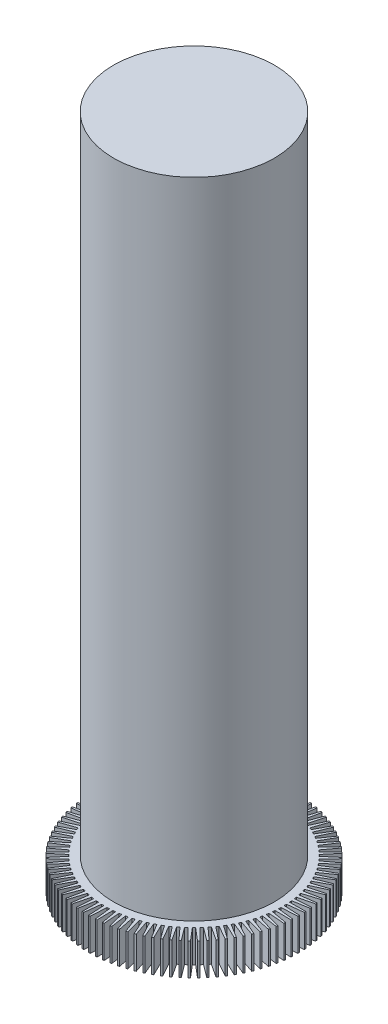
from build123d import *

# Parameters (mm, degrees)
BOSS_EXTRUDE2_DEPTH = 1
SKETCH2_R           = 2.5
BOSS_EXTRUDE3_DEPTH = 20


with BuildPart() as part:
    # Sketch1 → Boss-Extrude2 (new body)
    with BuildSketch(Plane(origin=(0, 0, 0), x_dir=(1, 0, 0), z_dir=(0, 1, 0))):
        with BuildLine():
            Line((-0.025, 3.249545417), (-0.05, 2.749545417))
            ThreePointArc((-0.05, 2.749545417), (-0.086379587, 2.748643041), (-0.122744049, 2.747259343))
            Line((-0.122744049, 2.747259343), (-0.179089977, 3.244702944))
            Line((-0.179089977, 3.244702944), (-0.228991313, 3.241563418))
            Line((-0.228991313, 3.241563418), (-0.222546722, 2.740980291))
            ThreePointArc((-0.222546722, 2.740980291), (-0.258797862, 2.737795403), (-0.295003683, 2.734131092))
            Line((-0.295003683, 2.734131092), (-0.382473167, 3.227055112))
            Line((-0.382473167, 3.227055112), (-0.432078902, 3.22078845))
            Line((-0.432078902, 3.22078845), (-0.394215153, 2.721597768))
            ThreePointArc((-0.394215153, 2.721597768), (-0.430194779, 2.716142937), (-0.466099072, 2.710212474))
            Line((-0.466099072, 2.710212474), (-0.584346911, 3.196671567))
            Line((-0.584346911, 3.196671567), (-0.633461273, 3.187302501))
            Line((-0.633461273, 3.187302501), (-0.564327797, 2.691474343))
            ThreePointArc((-0.564327797, 2.691474343), (-0.599893914, 2.683771095), (-0.635354981, 2.675597886))
            Line((-0.635354981, 2.675597886), (-0.783914504, 3.153672219))
            Line((-0.783914504, 3.153672219), (-0.832343662, 3.141237725))
            Line((-0.832343662, 3.141237725), (-0.732213298, 2.650728897))
            ThreePointArc((-0.732213298, 2.650728897), (-0.767225542, 2.640807636), (-0.802103435, 2.630423935))
            Line((-0.802103435, 2.630423935), (-0.980388345, 3.098226769))
            Line((-0.980388345, 3.098226769), (-1.027941171, 3.082775919))
            Line((-1.027941171, 3.082775919), (-0.897209086, 2.599522236))
            ThreePointArc((-0.897209086, 2.599522236), (-0.931529281, 2.587422115), (-0.965686352, 2.574868903))
            Line((-0.965686352, 2.574868903), (-1.172993041, 3.030554032))
            Line((-1.172993041, 3.030554032), (-1.219481865, 3.012147805))
            Line((-1.219481865, 3.012147805), (-1.058664001, 2.538056448))
            ThreePointArc((-1.058664001, 2.538056448), (-1.092156699, 2.523825221), (-1.125458147, 2.50915204))
            Line((-1.125458147, 2.50915204), (-1.360968469, 2.950921084))
            Line((-1.360968469, 2.950921084), (-1.406209822, 2.929632119))
            Line((-1.406209822, 2.929632119), (-1.215940852, 2.466574111))
            ThreePointArc((-1.215940852, 2.466574111), (-1.248473874, 2.450267942), (-1.280788273, 2.4335327))
            Line((-1.280788273, 2.4335327), (-1.543572777, 2.859642198))
            Line((-1.543572777, 2.859642198), (-1.587388111, 2.835554514))
            Line((-1.587388111, 2.835554514), (-1.368418941, 2.385357332))
            ThreePointArc((-1.368418941, 2.385357332), (-1.399863893, 2.367040574), (-1.431063712, 2.348309318))
            Line((-1.431063712, 2.348309318), (-1.720085308, 2.757077611))
            Line((-1.720085308, 2.757077611), (-1.762301704, 2.730286271))
            Line((-1.762301704, 2.730286271), (-1.515496505, 2.294726638))
            ThreePointArc((-1.515496505, 2.294726638), (-1.545729289, 2.274471579), (-1.575691397, 2.253818232))
            Line((-1.575691397, 2.253818232), (-1.889809448, 2.643632098))
            Line((-1.889809448, 2.643632098), (-1.930260298, 2.614242835))
            Line((-1.930260298, 2.614242835), (-1.656593096, 2.195039707))
            ThreePointArc((-1.656593096, 2.195039707), (-1.685494398, 2.172926284), (-1.714100548, 2.150432355))
            Line((-1.714100548, 2.150432355), (-2.052075373, 2.519753377))
            Line((-2.052075373, 2.519753377), (-2.090601036, 2.487882177))
            Line((-2.090601036, 2.487882177), (-1.791151872, 2.086689956))
            ThreePointArc((-1.791151872, 2.086689956), (-1.81860763, 2.062805441), (-1.845744926, 2.038559704))
            Line((-1.845744926, 2.038559704), (-2.206242695, 2.38593034))
            Line((-2.206242695, 2.38593034), (-2.242691126, 2.351702985))
            Line((-2.242691126, 2.351702985), (-1.918641789, 1.970104993))
            ThreePointArc((-1.918641789, 1.970104993), (-1.944543648, 1.944543648), (-1.970104993, 1.918641789))
            Line((-1.970104993, 1.918641789), (-2.351702985, 2.242691126))
            Line((-2.351702985, 2.242691126), (-2.38593034, 2.206242695))
            Line((-2.38593034, 2.206242695), (-2.038559704, 1.845744926))
            ThreePointArc((-2.038559704, 1.845744926), (-2.062805441, 1.81860763), (-2.086689956, 1.791151872))
            Line((-2.086689956, 1.791151872), (-2.487882177, 2.090601036))
            Line((-2.487882177, 2.090601036), (-2.519753377, 2.052075373))
            Line((-2.519753377, 2.052075373), (-2.150432355, 1.714100548))
            ThreePointArc((-2.150432355, 1.714100548), (-2.172926284, 1.685494398), (-2.195039707, 1.656593096))
            Line((-2.195039707, 1.656593096), (-2.614242835, 1.930260298))
            Line((-2.614242835, 1.930260298), (-2.643632098, 1.889809448))
            Line((-2.643632098, 1.889809448), (-2.253818232, 1.575691397))
            ThreePointArc((-2.253818232, 1.575691397), (-2.274471579, 1.545729289), (-2.294726638, 1.515496505))
            Line((-2.294726638, 1.515496505), (-2.730286271, 1.762301704))
            Line((-2.730286271, 1.762301704), (-2.757077611, 1.720085308))
            Line((-2.757077611, 1.720085308), (-2.348309318, 1.431063712))
            ThreePointArc((-2.348309318, 1.431063712), (-2.367040574, 1.399863893), (-2.385357332, 1.368418941))
            Line((-2.385357332, 1.368418941), (-2.835554514, 1.587388111))
            Line((-2.835554514, 1.587388111), (-2.859642198, 1.543572777))
            Line((-2.859642198, 1.543572777), (-2.4335327, 1.280788273))
            ThreePointArc((-2.4335327, 1.280788273), (-2.450267942, 1.248473874), (-2.466574111, 1.215940852))
            Line((-2.466574111, 1.215940852), (-2.929632119, 1.406209822))
            Line((-2.929632119, 1.406209822), (-2.950921084, 1.360968469))
            Line((-2.950921084, 1.360968469), (-2.50915204, 1.125458147))
            ThreePointArc((-2.50915204, 1.125458147), (-2.523825221, 1.092156699), (-2.538056448, 1.058664001))
            Line((-2.538056448, 1.058664001), (-3.012147805, 1.219481865))
            Line((-3.012147805, 1.219481865), (-3.030554032, 1.172993041))
            Line((-3.030554032, 1.172993041), (-2.574868903, 0.965686352))
            ThreePointArc((-2.574868903, 0.965686352), (-2.587422115, 0.931529281), (-2.599522236, 0.897209086))
            Line((-2.599522236, 0.897209086), (-3.082775919, 1.027941171))
            Line((-3.082775919, 1.027941171), (-3.098226769, 0.980388345))
            Line((-3.098226769, 0.980388345), (-2.630423935, 0.802103435))
            ThreePointArc((-2.630423935, 0.802103435), (-2.640807636, 0.767225542), (-2.650728897, 0.732213298))
            Line((-2.650728897, 0.732213298), (-3.141237725, 0.832343662))
            Line((-3.141237725, 0.832343662), (-3.153672219, 0.783914504))
            Line((-3.153672219, 0.783914504), (-2.675597886, 0.635354981))
            ThreePointArc((-2.675597886, 0.635354981), (-2.683771095, 0.599893914), (-2.691474343, 0.564327797))
            Line((-2.691474343, 0.564327797), (-3.187302501, 0.633461273))
            Line((-3.187302501, 0.633461273), (-3.196671567, 0.584346911))
            Line((-3.196671567, 0.584346911), (-2.710212474, 0.466099072))
            ThreePointArc((-2.710212474, 0.466099072), (-2.716142937, 0.430194779), (-2.721597768, 0.394215153))
            Line((-2.721597768, 0.394215153), (-3.22078845, 0.432078902))
            Line((-3.22078845, 0.432078902), (-3.227055112, 0.382473167))
            Line((-3.227055112, 0.382473167), (-2.734131092, 0.295003683))
            ThreePointArc((-2.734131092, 0.295003683), (-2.737795403, 0.258797862), (-2.740980291, 0.222546722))
            Line((-2.740980291, 0.222546722), (-3.241563418, 0.228991313))
            Line((-3.241563418, 0.228991313), (-3.244702944, 0.179089977))
            Line((-3.244702944, 0.179089977), (-2.747259343, 0.122744049))
            ThreePointArc((-2.747259343, 0.122744049), (-2.748643041, 0.086379587), (-2.749545417, 0.05))
            Line((-2.749545417, 0.05), (-3.249545417, 0.025))
            Line((-3.249545417, 0.025), (-3.249545417, -0.025))
            Line((-3.249545417, -0.025), (-2.749545417, -0.05))
            ThreePointArc((-2.749545417, -0.05), (-2.748643041, -0.086379587), (-2.747259343, -0.122744049))
            Line((-2.747259343, -0.122744049), (-3.244702944, -0.179089977))
            Line((-3.244702944, -0.179089977), (-3.241563418, -0.228991313))
            Line((-3.241563418, -0.228991313), (-2.740980291, -0.222546722))
            ThreePointArc((-2.740980291, -0.222546722), (-2.737795403, -0.258797862), (-2.734131092, -0.295003683))
            Line((-2.734131092, -0.295003683), (-3.227055112, -0.382473167))
            Line((-3.227055112, -0.382473167), (-3.22078845, -0.432078902))
            Line((-3.22078845, -0.432078902), (-2.721597768, -0.394215153))
            ThreePointArc((-2.721597768, -0.394215153), (-2.716142937, -0.430194779), (-2.710212474, -0.466099072))
            Line((-2.710212474, -0.466099072), (-3.196671567, -0.584346911))
            Line((-3.196671567, -0.584346911), (-3.187302501, -0.633461273))
            Line((-3.187302501, -0.633461273), (-2.691474343, -0.564327797))
            ThreePointArc((-2.691474343, -0.564327797), (-2.683771095, -0.599893914), (-2.675597886, -0.635354981))
            Line((-2.675597886, -0.635354981), (-3.153672219, -0.783914504))
            Line((-3.153672219, -0.783914504), (-3.141237725, -0.832343662))
            Line((-3.141237725, -0.832343662), (-2.650728897, -0.732213298))
            ThreePointArc((-2.650728897, -0.732213298), (-2.640807636, -0.767225542), (-2.630423935, -0.802103435))
            Line((-2.630423935, -0.802103435), (-3.098226769, -0.980388345))
            Line((-3.098226769, -0.980388345), (-3.082775919, -1.027941171))
            Line((-3.082775919, -1.027941171), (-2.599522236, -0.897209086))
            ThreePointArc((-2.599522236, -0.897209086), (-2.587422115, -0.931529281), (-2.574868903, -0.965686352))
            Line((-2.574868903, -0.965686352), (-3.030554032, -1.172993041))
            Line((-3.030554032, -1.172993041), (-3.012147805, -1.219481865))
            Line((-3.012147805, -1.219481865), (-2.538056448, -1.058664001))
            ThreePointArc((-2.538056448, -1.058664001), (-2.523825221, -1.092156699), (-2.50915204, -1.125458147))
            Line((-2.50915204, -1.125458147), (-2.950921084, -1.360968469))
            Line((-2.950921084, -1.360968469), (-2.929632119, -1.406209822))
            Line((-2.929632119, -1.406209822), (-2.466574111, -1.215940852))
            ThreePointArc((-2.466574111, -1.215940852), (-2.450267942, -1.248473874), (-2.4335327, -1.280788273))
            Line((-2.4335327, -1.280788273), (-2.859642198, -1.543572777))
            Line((-2.859642198, -1.543572777), (-2.835554514, -1.587388111))
            Line((-2.835554514, -1.587388111), (-2.385357332, -1.368418941))
            ThreePointArc((-2.385357332, -1.368418941), (-2.367040574, -1.399863893), (-2.348309318, -1.431063712))
            Line((-2.348309318, -1.431063712), (-2.757077611, -1.720085308))
            Line((-2.757077611, -1.720085308), (-2.730286271, -1.762301704))
            Line((-2.730286271, -1.762301704), (-2.294726638, -1.515496505))
            ThreePointArc((-2.294726638, -1.515496505), (-2.274471579, -1.545729289), (-2.253818232, -1.575691397))
            Line((-2.253818232, -1.575691397), (-2.643632098, -1.889809448))
            Line((-2.643632098, -1.889809448), (-2.614242835, -1.930260298))
            Line((-2.614242835, -1.930260298), (-2.195039707, -1.656593096))
            ThreePointArc((-2.195039707, -1.656593096), (-2.172926284, -1.685494398), (-2.150432355, -1.714100548))
            Line((-2.150432355, -1.714100548), (-2.519753377, -2.052075373))
            Line((-2.519753377, -2.052075373), (-2.487882177, -2.090601036))
            Line((-2.487882177, -2.090601036), (-2.086689956, -1.791151872))
            ThreePointArc((-2.086689956, -1.791151872), (-2.062805441, -1.81860763), (-2.038559704, -1.845744926))
            Line((-2.038559704, -1.845744926), (-2.38593034, -2.206242695))
            Line((-2.38593034, -2.206242695), (-2.351702985, -2.242691126))
            Line((-2.351702985, -2.242691126), (-1.970104993, -1.918641789))
            ThreePointArc((-1.970104993, -1.918641789), (-1.944543648, -1.944543648), (-1.918641789, -1.970104993))
            Line((-1.918641789, -1.970104993), (-2.242691126, -2.351702985))
            Line((-2.242691126, -2.351702985), (-2.206242695, -2.38593034))
            Line((-2.206242695, -2.38593034), (-1.845744926, -2.038559704))
            ThreePointArc((-1.845744926, -2.038559704), (-1.81860763, -2.062805441), (-1.791151872, -2.086689956))
            Line((-1.791151872, -2.086689956), (-2.090601036, -2.487882177))
            Line((-2.090601036, -2.487882177), (-2.052075373, -2.519753377))
            Line((-2.052075373, -2.519753377), (-1.714100548, -2.150432355))
            ThreePointArc((-1.714100548, -2.150432355), (-1.685494398, -2.172926284), (-1.656593096, -2.195039707))
            Line((-1.656593096, -2.195039707), (-1.930260298, -2.614242835))
            Line((-1.930260298, -2.614242835), (-1.889809448, -2.643632098))
            Line((-1.889809448, -2.643632098), (-1.575691397, -2.253818232))
            ThreePointArc((-1.575691397, -2.253818232), (-1.545729289, -2.274471579), (-1.515496505, -2.294726638))
            Line((-1.515496505, -2.294726638), (-1.762301704, -2.730286271))
            Line((-1.762301704, -2.730286271), (-1.720085308, -2.757077611))
            Line((-1.720085308, -2.757077611), (-1.431063712, -2.348309318))
            ThreePointArc((-1.431063712, -2.348309318), (-1.399863893, -2.367040574), (-1.368418941, -2.385357332))
            Line((-1.368418941, -2.385357332), (-1.587388111, -2.835554514))
            Line((-1.587388111, -2.835554514), (-1.543572777, -2.859642198))
            Line((-1.543572777, -2.859642198), (-1.280788273, -2.4335327))
            ThreePointArc((-1.280788273, -2.4335327), (-1.248473874, -2.450267942), (-1.215940852, -2.466574111))
            Line((-1.215940852, -2.466574111), (-1.406209822, -2.929632119))
            Line((-1.406209822, -2.929632119), (-1.360968469, -2.950921084))
            Line((-1.360968469, -2.950921084), (-1.125458147, -2.50915204))
            ThreePointArc((-1.125458147, -2.50915204), (-1.092156699, -2.523825221), (-1.058664001, -2.538056448))
            Line((-1.058664001, -2.538056448), (-1.219481865, -3.012147805))
            Line((-1.219481865, -3.012147805), (-1.172993041, -3.030554032))
            Line((-1.172993041, -3.030554032), (-0.965686352, -2.574868903))
            ThreePointArc((-0.965686352, -2.574868903), (-0.931529281, -2.587422115), (-0.897209086, -2.599522236))
            Line((-0.897209086, -2.599522236), (-1.027941171, -3.082775919))
            Line((-1.027941171, -3.082775919), (-0.980388345, -3.098226769))
            Line((-0.980388345, -3.098226769), (-0.802103435, -2.630423935))
            ThreePointArc((-0.802103435, -2.630423935), (-0.767225542, -2.640807636), (-0.732213298, -2.650728897))
            Line((-0.732213298, -2.650728897), (-0.832343662, -3.141237725))
            Line((-0.832343662, -3.141237725), (-0.783914504, -3.153672219))
            Line((-0.783914504, -3.153672219), (-0.635354981, -2.675597886))
            ThreePointArc((-0.635354981, -2.675597886), (-0.599893914, -2.683771095), (-0.564327797, -2.691474343))
            Line((-0.564327797, -2.691474343), (-0.633461273, -3.187302501))
            Line((-0.633461273, -3.187302501), (-0.584346911, -3.196671567))
            Line((-0.584346911, -3.196671567), (-0.466099072, -2.710212474))
            ThreePointArc((-0.466099072, -2.710212474), (-0.430194779, -2.716142937), (-0.394215153, -2.721597768))
            Line((-0.394215153, -2.721597768), (-0.432078902, -3.22078845))
            Line((-0.432078902, -3.22078845), (-0.382473167, -3.227055112))
            Line((-0.382473167, -3.227055112), (-0.295003683, -2.734131092))
            ThreePointArc((-0.295003683, -2.734131092), (-0.258797862, -2.737795403), (-0.222546722, -2.740980291))
            Line((-0.222546722, -2.740980291), (-0.228991313, -3.241563418))
            Line((-0.228991313, -3.241563418), (-0.179089977, -3.244702944))
            Line((-0.179089977, -3.244702944), (-0.122744049, -2.747259343))
            ThreePointArc((-0.122744049, -2.747259343), (-0.086379587, -2.748643041), (-0.05, -2.749545417))
            Line((-0.05, -2.749545417), (-0.025, -3.249545417))
            Line((-0.025, -3.249545417), (0.025, -3.249545417))
            Line((0.025, -3.249545417), (0.05, -2.749545417))
            ThreePointArc((0.05, -2.749545417), (0.086379587, -2.748643041), (0.122744049, -2.747259343))
            Line((0.122744049, -2.747259343), (0.179089977, -3.244702944))
            Line((0.179089977, -3.244702944), (0.228991313, -3.241563418))
            Line((0.228991313, -3.241563418), (0.222546722, -2.740980291))
            ThreePointArc((0.222546722, -2.740980291), (0.258797862, -2.737795403), (0.295003683, -2.734131092))
            Line((0.295003683, -2.734131092), (0.382473167, -3.227055112))
            Line((0.382473167, -3.227055112), (0.432078902, -3.22078845))
            Line((0.432078902, -3.22078845), (0.394215153, -2.721597768))
            ThreePointArc((0.394215153, -2.721597768), (0.430194779, -2.716142937), (0.466099072, -2.710212474))
            Line((0.466099072, -2.710212474), (0.584346911, -3.196671567))
            Line((0.584346911, -3.196671567), (0.633461273, -3.187302501))
            Line((0.633461273, -3.187302501), (0.564327797, -2.691474343))
            ThreePointArc((0.564327797, -2.691474343), (0.599893914, -2.683771095), (0.635354981, -2.675597886))
            Line((0.635354981, -2.675597886), (0.783914504, -3.153672219))
            Line((0.783914504, -3.153672219), (0.832343662, -3.141237725))
            Line((0.832343662, -3.141237725), (0.732213298, -2.650728897))
            ThreePointArc((0.732213298, -2.650728897), (0.767225542, -2.640807636), (0.802103435, -2.630423935))
            Line((0.802103435, -2.630423935), (0.980388345, -3.098226769))
            Line((0.980388345, -3.098226769), (1.027941171, -3.082775919))
            Line((1.027941171, -3.082775919), (0.897209086, -2.599522236))
            ThreePointArc((0.897209086, -2.599522236), (0.931529281, -2.587422115), (0.965686352, -2.574868903))
            Line((0.965686352, -2.574868903), (1.172993041, -3.030554032))
            Line((1.172993041, -3.030554032), (1.219481865, -3.012147805))
            Line((1.219481865, -3.012147805), (1.058664001, -2.538056448))
            ThreePointArc((1.058664001, -2.538056448), (1.092156699, -2.523825221), (1.125458147, -2.50915204))
            Line((1.125458147, -2.50915204), (1.360968469, -2.950921084))
            Line((1.360968469, -2.950921084), (1.406209822, -2.929632119))
            Line((1.406209822, -2.929632119), (1.215940852, -2.466574111))
            ThreePointArc((1.215940852, -2.466574111), (1.248473874, -2.450267942), (1.280788273, -2.4335327))
            Line((1.280788273, -2.4335327), (1.543572777, -2.859642198))
            Line((1.543572777, -2.859642198), (1.587388111, -2.835554514))
            Line((1.587388111, -2.835554514), (1.368418941, -2.385357332))
            ThreePointArc((1.368418941, -2.385357332), (1.399863893, -2.367040574), (1.431063712, -2.348309318))
            Line((1.431063712, -2.348309318), (1.720085308, -2.757077611))
            Line((1.720085308, -2.757077611), (1.762301704, -2.730286271))
            Line((1.762301704, -2.730286271), (1.515496505, -2.294726638))
            ThreePointArc((1.515496505, -2.294726638), (1.545729289, -2.274471579), (1.575691397, -2.253818232))
            Line((1.575691397, -2.253818232), (1.889809448, -2.643632098))
            Line((1.889809448, -2.643632098), (1.930260298, -2.614242835))
            Line((1.930260298, -2.614242835), (1.656593096, -2.195039707))
            ThreePointArc((1.656593096, -2.195039707), (1.685494398, -2.172926284), (1.714100548, -2.150432355))
            Line((1.714100548, -2.150432355), (2.052075373, -2.519753377))
            Line((2.052075373, -2.519753377), (2.090601036, -2.487882177))
            Line((2.090601036, -2.487882177), (1.791151872, -2.086689956))
            ThreePointArc((1.791151872, -2.086689956), (1.81860763, -2.062805441), (1.845744926, -2.038559704))
            Line((1.845744926, -2.038559704), (2.206242695, -2.38593034))
            Line((2.206242695, -2.38593034), (2.242691126, -2.351702985))
            Line((2.242691126, -2.351702985), (1.918641789, -1.970104993))
            ThreePointArc((1.918641789, -1.970104993), (1.944543648, -1.944543648), (1.970104993, -1.918641789))
            Line((1.970104993, -1.918641789), (2.351702985, -2.242691126))
            Line((2.351702985, -2.242691126), (2.38593034, -2.206242695))
            Line((2.38593034, -2.206242695), (2.038559704, -1.845744926))
            ThreePointArc((2.038559704, -1.845744926), (2.062805441, -1.81860763), (2.086689956, -1.791151872))
            Line((2.086689956, -1.791151872), (2.487882177, -2.090601036))
            Line((2.487882177, -2.090601036), (2.519753377, -2.052075373))
            Line((2.519753377, -2.052075373), (2.150432355, -1.714100548))
            ThreePointArc((2.150432355, -1.714100548), (2.172926284, -1.685494398), (2.195039707, -1.656593096))
            Line((2.195039707, -1.656593096), (2.614242835, -1.930260298))
            Line((2.614242835, -1.930260298), (2.643632098, -1.889809448))
            Line((2.643632098, -1.889809448), (2.253818232, -1.575691397))
            ThreePointArc((2.253818232, -1.575691397), (2.274471579, -1.545729289), (2.294726638, -1.515496505))
            Line((2.294726638, -1.515496505), (2.730286271, -1.762301704))
            Line((2.730286271, -1.762301704), (2.757077611, -1.720085308))
            Line((2.757077611, -1.720085308), (2.348309318, -1.431063712))
            ThreePointArc((2.348309318, -1.431063712), (2.367040574, -1.399863893), (2.385357332, -1.368418941))
            Line((2.385357332, -1.368418941), (2.835554514, -1.587388111))
            Line((2.835554514, -1.587388111), (2.859642198, -1.543572777))
            Line((2.859642198, -1.543572777), (2.4335327, -1.280788273))
            ThreePointArc((2.4335327, -1.280788273), (2.450267942, -1.248473874), (2.466574111, -1.215940852))
            Line((2.466574111, -1.215940852), (2.929632119, -1.406209822))
            Line((2.929632119, -1.406209822), (2.950921084, -1.360968469))
            Line((2.950921084, -1.360968469), (2.50915204, -1.125458147))
            ThreePointArc((2.50915204, -1.125458147), (2.523825221, -1.092156699), (2.538056448, -1.058664001))
            Line((2.538056448, -1.058664001), (3.012147805, -1.219481865))
            Line((3.012147805, -1.219481865), (3.030554032, -1.172993041))
            Line((3.030554032, -1.172993041), (2.574868903, -0.965686352))
            ThreePointArc((2.574868903, -0.965686352), (2.587422115, -0.931529281), (2.599522236, -0.897209086))
            Line((2.599522236, -0.897209086), (3.082775919, -1.027941171))
            Line((3.082775919, -1.027941171), (3.098226769, -0.980388345))
            Line((3.098226769, -0.980388345), (2.630423935, -0.802103435))
            ThreePointArc((2.630423935, -0.802103435), (2.640807636, -0.767225542), (2.650728897, -0.732213298))
            Line((2.650728897, -0.732213298), (3.141237725, -0.832343662))
            Line((3.141237725, -0.832343662), (3.153672219, -0.783914504))
            Line((3.153672219, -0.783914504), (2.675597886, -0.635354981))
            ThreePointArc((2.675597886, -0.635354981), (2.683771095, -0.599893914), (2.691474343, -0.564327797))
            Line((2.691474343, -0.564327797), (3.187302501, -0.633461273))
            Line((3.187302501, -0.633461273), (3.196671567, -0.584346911))
            Line((3.196671567, -0.584346911), (2.710212474, -0.466099072))
            ThreePointArc((2.710212474, -0.466099072), (2.716142937, -0.430194779), (2.721597768, -0.394215153))
            Line((2.721597768, -0.394215153), (3.22078845, -0.432078902))
            Line((3.22078845, -0.432078902), (3.227055112, -0.382473167))
            Line((3.227055112, -0.382473167), (2.734131092, -0.295003683))
            ThreePointArc((2.734131092, -0.295003683), (2.737795403, -0.258797862), (2.740980291, -0.222546722))
            Line((2.740980291, -0.222546722), (3.241563418, -0.228991313))
            Line((3.241563418, -0.228991313), (3.244702944, -0.179089977))
            Line((3.244702944, -0.179089977), (2.747259343, -0.122744049))
            ThreePointArc((2.747259343, -0.122744049), (2.748643041, -0.086379587), (2.749545417, -0.05))
            Line((2.749545417, -0.05), (3.249545417, -0.025))
            Line((3.249545417, -0.025), (3.249545417, 0.025))
            Line((3.249545417, 0.025), (2.749545417, 0.05))
            ThreePointArc((2.749545417, 0.05), (2.748643041, 0.086379587), (2.747259343, 0.122744049))
            Line((2.747259343, 0.122744049), (3.244702944, 0.179089977))
            Line((3.244702944, 0.179089977), (3.241563418, 0.228991313))
            Line((3.241563418, 0.228991313), (2.740980291, 0.222546722))
            ThreePointArc((2.740980291, 0.222546722), (2.737795403, 0.258797862), (2.734131092, 0.295003683))
            Line((2.734131092, 0.295003683), (3.227055112, 0.382473167))
            Line((3.227055112, 0.382473167), (3.22078845, 0.432078902))
            Line((3.22078845, 0.432078902), (2.721597768, 0.394215153))
            ThreePointArc((2.721597768, 0.394215153), (2.716142937, 0.430194779), (2.710212474, 0.466099072))
            Line((2.710212474, 0.466099072), (3.196671567, 0.584346911))
            Line((3.196671567, 0.584346911), (3.187302501, 0.633461273))
            Line((3.187302501, 0.633461273), (2.691474343, 0.564327797))
            ThreePointArc((2.691474343, 0.564327797), (2.683771095, 0.599893914), (2.675597886, 0.635354981))
            Line((2.675597886, 0.635354981), (3.153672219, 0.783914504))
            Line((3.153672219, 0.783914504), (3.141237725, 0.832343662))
            Line((3.141237725, 0.832343662), (2.650728897, 0.732213298))
            ThreePointArc((2.650728897, 0.732213298), (2.640807636, 0.767225542), (2.630423935, 0.802103435))
            Line((2.630423935, 0.802103435), (3.098226769, 0.980388345))
            Line((3.098226769, 0.980388345), (3.082775919, 1.027941171))
            Line((3.082775919, 1.027941171), (2.599522236, 0.897209086))
            ThreePointArc((2.599522236, 0.897209086), (2.587422115, 0.931529281), (2.574868903, 0.965686352))
            Line((2.574868903, 0.965686352), (3.030554032, 1.172993041))
            Line((3.030554032, 1.172993041), (3.012147805, 1.219481865))
            Line((3.012147805, 1.219481865), (2.538056448, 1.058664001))
            ThreePointArc((2.538056448, 1.058664001), (2.523825221, 1.092156699), (2.50915204, 1.125458147))
            Line((2.50915204, 1.125458147), (2.950921084, 1.360968469))
            Line((2.950921084, 1.360968469), (2.929632119, 1.406209822))
            Line((2.929632119, 1.406209822), (2.466574111, 1.215940852))
            ThreePointArc((2.466574111, 1.215940852), (2.450267942, 1.248473874), (2.4335327, 1.280788273))
            Line((2.4335327, 1.280788273), (2.859642198, 1.543572777))
            Line((2.859642198, 1.543572777), (2.835554514, 1.587388111))
            Line((2.835554514, 1.587388111), (2.385357332, 1.368418941))
            ThreePointArc((2.385357332, 1.368418941), (2.367040574, 1.399863893), (2.348309318, 1.431063712))
            Line((2.348309318, 1.431063712), (2.757077611, 1.720085308))
            Line((2.757077611, 1.720085308), (2.730286271, 1.762301704))
            Line((2.730286271, 1.762301704), (2.294726638, 1.515496505))
            ThreePointArc((2.294726638, 1.515496505), (2.274471579, 1.545729289), (2.253818232, 1.575691397))
            Line((2.253818232, 1.575691397), (2.643632098, 1.889809448))
            Line((2.643632098, 1.889809448), (2.614242835, 1.930260298))
            Line((2.614242835, 1.930260298), (2.195039707, 1.656593096))
            ThreePointArc((2.195039707, 1.656593096), (2.172926284, 1.685494398), (2.150432355, 1.714100548))
            Line((2.150432355, 1.714100548), (2.519753377, 2.052075373))
            Line((2.519753377, 2.052075373), (2.487882177, 2.090601036))
            Line((2.487882177, 2.090601036), (2.086689956, 1.791151872))
            ThreePointArc((2.086689956, 1.791151872), (2.062805441, 1.81860763), (2.038559704, 1.845744926))
            Line((2.038559704, 1.845744926), (2.38593034, 2.206242695))
            Line((2.38593034, 2.206242695), (2.351702985, 2.242691126))
            Line((2.351702985, 2.242691126), (1.970104993, 1.918641789))
            ThreePointArc((1.970104993, 1.918641789), (1.944543648, 1.944543648), (1.918641789, 1.970104993))
            Line((1.918641789, 1.970104993), (2.242691126, 2.351702985))
            Line((2.242691126, 2.351702985), (2.206242695, 2.38593034))
            Line((2.206242695, 2.38593034), (1.845744926, 2.038559704))
            ThreePointArc((1.845744926, 2.038559704), (1.81860763, 2.062805441), (1.791151872, 2.086689956))
            Line((1.791151872, 2.086689956), (2.090601036, 2.487882177))
            Line((2.090601036, 2.487882177), (2.052075373, 2.519753377))
            Line((2.052075373, 2.519753377), (1.714100548, 2.150432355))
            ThreePointArc((1.714100548, 2.150432355), (1.685494398, 2.172926284), (1.656593096, 2.195039707))
            Line((1.656593096, 2.195039707), (1.930260298, 2.614242835))
            Line((1.930260298, 2.614242835), (1.889809448, 2.643632098))
            Line((1.889809448, 2.643632098), (1.575691397, 2.253818232))
            ThreePointArc((1.575691397, 2.253818232), (1.545729289, 2.274471579), (1.515496505, 2.294726638))
            Line((1.515496505, 2.294726638), (1.762301704, 2.730286271))
            Line((1.762301704, 2.730286271), (1.720085308, 2.757077611))
            Line((1.720085308, 2.757077611), (1.431063712, 2.348309318))
            ThreePointArc((1.431063712, 2.348309318), (1.399863893, 2.367040574), (1.368418941, 2.385357332))
            Line((1.368418941, 2.385357332), (1.587388111, 2.835554514))
            Line((1.587388111, 2.835554514), (1.543572777, 2.859642198))
            Line((1.543572777, 2.859642198), (1.280788273, 2.4335327))
            ThreePointArc((1.280788273, 2.4335327), (1.248473874, 2.450267942), (1.215940852, 2.466574111))
            Line((1.215940852, 2.466574111), (1.406209822, 2.929632119))
            Line((1.406209822, 2.929632119), (1.360968469, 2.950921084))
            Line((1.360968469, 2.950921084), (1.125458147, 2.50915204))
            ThreePointArc((1.125458147, 2.50915204), (1.092156699, 2.523825221), (1.058664001, 2.538056448))
            Line((1.058664001, 2.538056448), (1.219481865, 3.012147805))
            Line((1.219481865, 3.012147805), (1.172993041, 3.030554032))
            Line((1.172993041, 3.030554032), (0.965686352, 2.574868903))
            ThreePointArc((0.965686352, 2.574868903), (0.931529281, 2.587422115), (0.897209086, 2.599522236))
            Line((0.897209086, 2.599522236), (1.027941171, 3.082775919))
            Line((1.027941171, 3.082775919), (0.980388345, 3.098226769))
            Line((0.980388345, 3.098226769), (0.802103435, 2.630423935))
            ThreePointArc((0.802103435, 2.630423935), (0.767225542, 2.640807636), (0.732213298, 2.650728897))
            Line((0.732213298, 2.650728897), (0.832343662, 3.141237725))
            Line((0.832343662, 3.141237725), (0.783914504, 3.153672219))
            Line((0.783914504, 3.153672219), (0.635354981, 2.675597886))
            ThreePointArc((0.635354981, 2.675597886), (0.599893914, 2.683771095), (0.564327797, 2.691474343))
            Line((0.564327797, 2.691474343), (0.633461273, 3.187302501))
            Line((0.633461273, 3.187302501), (0.584346911, 3.196671567))
            Line((0.584346911, 3.196671567), (0.466099072, 2.710212474))
            ThreePointArc((0.466099072, 2.710212474), (0.430194779, 2.716142937), (0.394215153, 2.721597768))
            Line((0.394215153, 2.721597768), (0.432078902, 3.22078845))
            Line((0.432078902, 3.22078845), (0.382473167, 3.227055112))
            Line((0.382473167, 3.227055112), (0.295003683, 2.734131092))
            ThreePointArc((0.295003683, 2.734131092), (0.258797862, 2.737795403), (0.222546722, 2.740980291))
            Line((0.222546722, 2.740980291), (0.228991313, 3.241563418))
            Line((0.228991313, 3.241563418), (0.179089977, 3.244702944))
            Line((0.179089977, 3.244702944), (0.122744049, 2.747259343))
            ThreePointArc((0.122744049, 2.747259343), (0.086379587, 2.748643041), (0.05, 2.749545417))
            Line((0.05, 2.749545417), (0.025, 3.249545417))
            Line((0.025, 3.249545417), (-0.025, 3.249545417))
        make_face()
    extrude(amount=BOSS_EXTRUDE2_DEPTH)

    # Sketch2 → Boss-Extrude3 (add)
    with BuildSketch(Plane(origin=(0, 1, 0), x_dir=(1, 0, 0), z_dir=(0, 1, 0))):
        Circle(SKETCH2_R)
    extrude(amount=BOSS_EXTRUDE3_DEPTH)


solid = part.part
